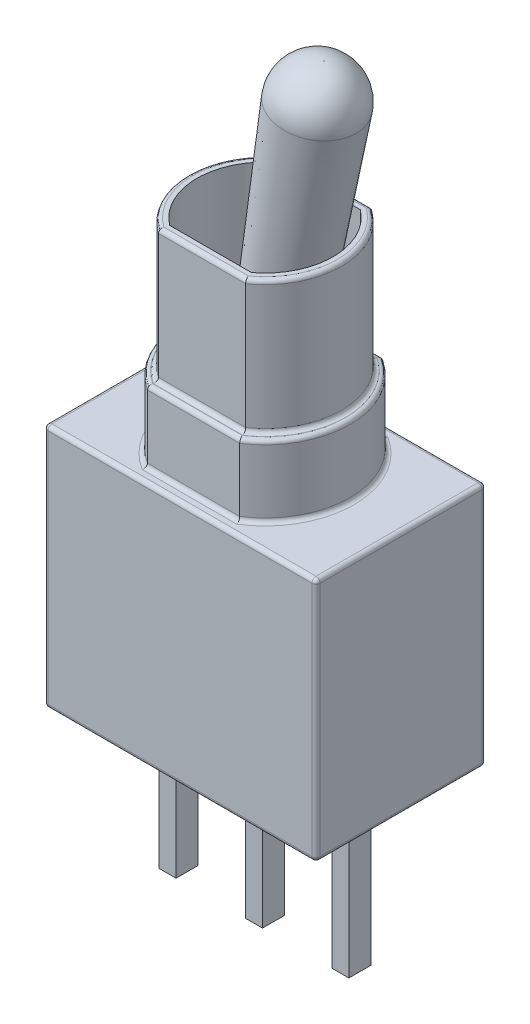
from build123d import *

# Parameters (mm, degrees)
BOSS_EXTRUDE1_DEPTH = 7.2
SKETCH2_W           = 2.712931993250106
SKETCH2_H           = 4.2
BOSS_EXTRUDE2_DEPTH = 2.1
BOSS_EXTRUDE3_DEPTH = 3.9
CUT_EXTRUDE1_DEPTH  = 6
SKETCH6_R           = 1.2
SKETCH5_R           = 0.9
FILLET1_R           = 1.15
BOSS_EXTRUDE4_DEPTH = 4.6
FILLET2_R           = 0.12


with BuildPart() as part:
    # Sketch1 → Boss-Extrude1 (new body)
    with BuildSketch(Plane(origin=(0, 0, 0), x_dir=(1, 0, 0), z_dir=(0, 1, 0))):
        Polygon((-3.999999999999999, 2.5), (4.000000000000001, 2.5), (4.000000000000003, -2.5), (-3.9999999999999982, -2.5), align=None)
    extrude(amount=BOSS_EXTRUDE1_DEPTH)

    # Sketch2 → Boss-Extrude2 (add)
    with BuildSketch(Plane(origin=(0, 7.2, 0), x_dir=(1, 0, 0), z_dir=(0, 1, 0))):
        with BuildLine():
            ThreePointArc((-1.3564659966250532, 2.1000000000000005), (-2.5, 3.1e-16), (-1.3564659966250527, -2.1000000000000005))
            Line((-1.3564659966250527, -2.1), (-1.3564659966250527, 2.1))
        make_face()
        Rectangle(SKETCH2_W, SKETCH2_H)
        with BuildLine():
            Line((1.3564659966250532, 2.1), (1.3564659966250532, -2.1))
            ThreePointArc((1.3564659966250519, -2.100000000000001), (2.1955824957813164, -1.1955824957813181), (2.5, -6.1e-16))
            ThreePointArc((2.5, 0), (2.195582495781317, 1.1955824957813173), (1.3564659966250532, 2.1))
        make_face()
    extrude(amount=BOSS_EXTRUDE2_DEPTH)

    # Sketch3 → Boss-Extrude3 (add)
    with BuildSketch(Plane(origin=(0, 9.299999999999999, 0), x_dir=(1, 0, 0), z_dir=(0, 1, 0))):
        with BuildLine():
            Line((-1.2806248474869384, -1.8500000000000003), (1.28062484748694, -1.8500000000000003))
            ThreePointArc((1.28062484748694, -1.8500000000000003), (2.250000000000211, 0), (1.2806248474869395, 1.8500000000000003))
            Line((1.2806248474869395, 1.8500000000000003), (-1.2806248474869382, 1.8500000000000003))
            ThreePointArc((-1.2806248474869382, 1.8500000000000003), (-2.25000000000021, 2.8e-16), (-1.2806248474869384, -1.8500000000000003))
        make_face()
    extrude(amount=BOSS_EXTRUDE3_DEPTH)

    # Sketch4 → Cut-Extrude1 (cut)
    with BuildSketch(Plane(origin=(0, 13.2, 0), x_dir=(1, 0, 0), z_dir=(0, 1, 0))):
        with BuildLine():
            Line((1.200000000001133, 1.6000000000000003), (-1.200000000001132, 1.6000000000000003))
            ThreePointArc((-1.200000000001132, 1.6000000000000003), (-2.0000000000006795, 2.4e-16), (-1.200000000001132, -1.6000000000000003))
            Line((-1.200000000001132, -1.6000000000000003), (1.2000000000011335, -1.6000000000000003))
            ThreePointArc((1.2000000000011335, -1.6000000000000003), (2.0000000000006803, 2.2e-16), (1.200000000001133, 1.6000000000000003))
        make_face()
    extrude(amount=-CUT_EXTRUDE1_DEPTH, mode=Mode.SUBTRACT)

    # Sketch7 → Boss-Extrude4 (add)
    with BuildSketch(Plane.XZ):
        Polygon((2.790000000000003, 0.3249999999999992), (2.790000000000003, -0.3250000000000008), (2.290000000000003, -0.3250000000000008), (2.290000000000003, 0.3249999999999991), align=None)
        Polygon((-0.2500000000000001, 0.32499999999999996), (0.2499999999999999, 0.32499999999999996), (0.25000000000000006, -0.325), (-0.25000000000000006, -0.325), align=None)
        Polygon((-2.7900000000000005, 0.32500000000000007), (-2.2900000000000005, 0.325), (-2.2900000000000005, -0.32499999999999996), (-2.7900000000000005, -0.32499999999999996), align=None)
    extrude(amount=BOSS_EXTRUDE4_DEPTH)

    # Fillet2
    fillet2_edges = [part.edges().sort_by_distance(p)[0] for p in [
        (-3.9999999999999987, 7.2, 0),
        (2.66e-15, 7.2, 2.5),
        (-2.499999999999999, 7.2, 2.2e-16),
        (2.2e-16, 9.3, 2.1),
        (2.5, 7.2, 6.7e-16),
        (2.2e-16, 7.2, -2.1),
        (-2.499999999999999, 9.3, 2.2e-16),
        (2.5, 9.3, 4.4e-16),
        (2.2e-16, 9.3, -2.1),
        (2.2e-16, 7.2, 2.1),
        (-2.25000000000021, 9.299999999999999, -2.2e-16),
        (8.9e-16, 9.299999999999999, 1.8500000000000003),
        (2.2500000000002114, 9.299999999999999, -2.2e-16),
        (6.7e-16, 9.299999999999999, -1.8500000000000003),
        (6.7e-16, 13.2, -1.8500000000000003),
        (-2.25000000000021, 13.2, -2.2e-16),
        (8.9e-16, 13.2, 1.8500000000000003),
        (2.2500000000002114, 13.2, -2.2e-16),
        (4.000000000000002, 7.2, 0),
        (2.66e-15, 0, 2.5),
        (-3.9999999999999987, 0, 0),
        (8.9e-16, 0, -2.5),
        (4.000000000000002, 0, 0),
        (8.9e-16, 7.2, -2.5),
        (4.000000000000003, 3.6, 2.5),
        (-3.9999999999999982, 3.6, 2.5),
        (-3.999999999999999, 3.6, -2.5),
        (4.000000000000001, 3.6, -2.5),
    ]]
    fillet(fillet2_edges, radius=FILLET2_R)


with BuildPart() as body_2:
    # Sketch6 → Loft1 section 0
    with BuildSketch(Plane(origin=(3.1387643643044916, 17.80081727534432, 0), x_dir=(0, 0, 1), z_dir=(-0.17364817766692736, -0.9848077530122086, 0))):
        with Locations((0, 1.4239150568688042)):
            Circle(SKETCH6_R)
    # Sketch5 → Loft1 section 1
    with BuildSketch(Plane(origin=(1.4022825876352183, 7.952739745222232, 0), x_dir=(0, 0, 1), z_dir=(-0.17364817766692736, -0.9848077530122086, 0))):
        with Locations((0, 1.4239150568688042)):
            Circle(SKETCH5_R)
    loft()

    # Fillet1
    fillet1_edges = [body_2.edges().sort_by_distance(p)[0] for p in [
        (1.736481776669273, 18.048077530122086, -1.2),
    ]]
    fillet(fillet1_edges, radius=FILLET1_R)


solid = Compound([part.part, body_2.part])
